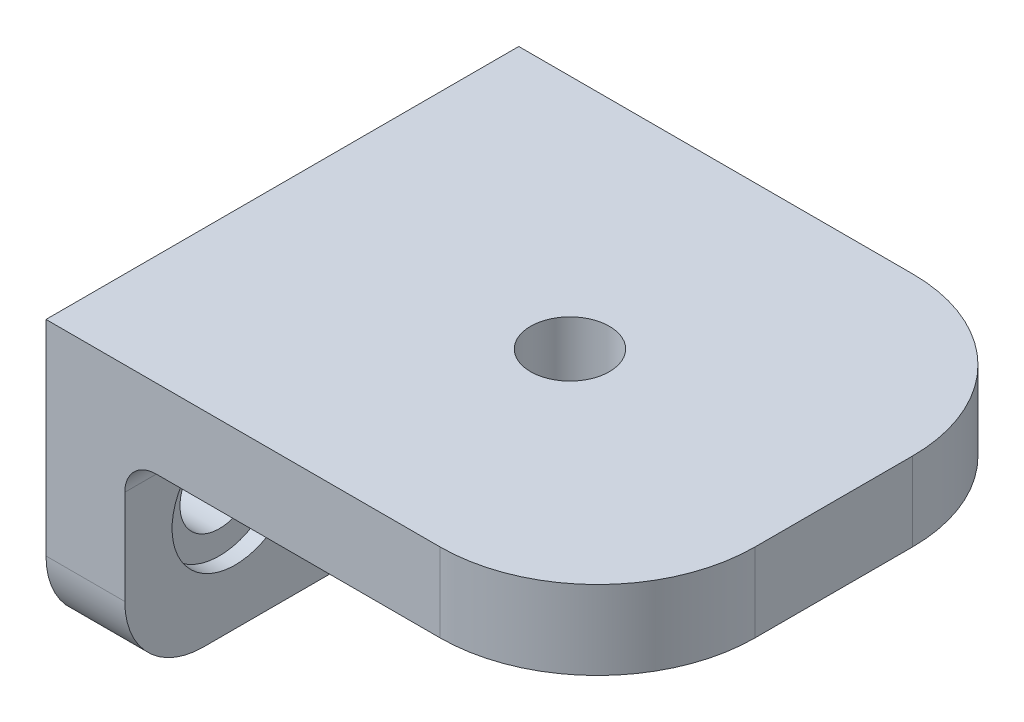
from build123d import *

# Parameters (mm, degrees)
SKETCH1_W           = 30
SKETCH1_H           = 30
BOSS_EXTRUDE1_DEPTH = 5
SKETCH2_W           = 30
SKETCH2_H           = 18
BOSS_EXTRUDE2_DEPTH = 5
SKETCH3_R           = 4
CUT_EXTRUDE1_DEPTH  = 1
SKETCH4_R           = 2.5
CUT_EXTRUDE2_DEPTH  = 5
SKETCH5_R           = 2.5
CUT_EXTRUDE3_DEPTH  = 5
FILLET1_R           = 10
FILLET2_R           = 2
FILLET3_R           = 5


with BuildPart() as part:
    # Sketch1 → Boss-Extrude1 (new body)
    with BuildSketch(Plane(origin=(0, 0, 0), x_dir=(1, 0, 0), z_dir=(0, 1, 0))):
        Rectangle(SKETCH1_W, SKETCH1_H)
    extrude(amount=BOSS_EXTRUDE1_DEPTH)

    # Sketch2 → Boss-Extrude2 (add)
    with BuildSketch(Plane.ZY.offset(15)):
        with Locations((0, -4)):
            Rectangle(SKETCH2_W, SKETCH2_H)
    extrude(amount=BOSS_EXTRUDE2_DEPTH)

    # Sketch3 → Cut-Extrude1 (cut)
    with BuildSketch(Plane(origin=(-15, 0, 0), x_dir=(0, 0, -1), z_dir=(1, 0, 0))):
        with Locations((-8, -5.5)):
            Circle(SKETCH3_R)
        with Locations((8, -5.5)):
            Circle(SKETCH3_R)
    extrude(amount=-CUT_EXTRUDE1_DEPTH, mode=Mode.SUBTRACT)

    # Sketch4 → Cut-Extrude2 (cut)
    with BuildSketch(Plane(origin=(-16, 0, 0), x_dir=(0, 0, -1), z_dir=(1, 0, 0))):
        with Locations((-8, -5.5)):
            Circle(SKETCH4_R)
        with Locations((8, -5.5)):
            Circle(SKETCH4_R)
    extrude(amount=-CUT_EXTRUDE2_DEPTH, mode=Mode.SUBTRACT)

    # Sketch5 → Cut-Extrude3 (cut)
    with BuildSketch(Plane(origin=(0, 5, 0), x_dir=(1, 0, 0), z_dir=(0, 1, 0))):
        with Locations((-1.75, 0)):
            Circle(SKETCH5_R)
    extrude(amount=-CUT_EXTRUDE3_DEPTH, mode=Mode.SUBTRACT)

    # Fillet1
    fillet1_edges = [part.edges().sort_by_distance(p)[0] for p in [
        (15, 2.5, -15),
        (15, 2.5, 15),
    ]]
    fillet(fillet1_edges, radius=FILLET1_R)

    # Fillet2
    fillet2_edges = [part.edges().sort_by_distance(p)[0] for p in [
        (-15, 0, 0),
    ]]
    fillet(fillet2_edges, radius=FILLET2_R)

    # Fillet3
    fillet3_edges = [part.edges().sort_by_distance(p)[0] for p in [
        (-17.5, -13, -15),
        (-17.5, -13, 15),
    ]]
    fillet(fillet3_edges, radius=FILLET3_R)


solid = part.part
